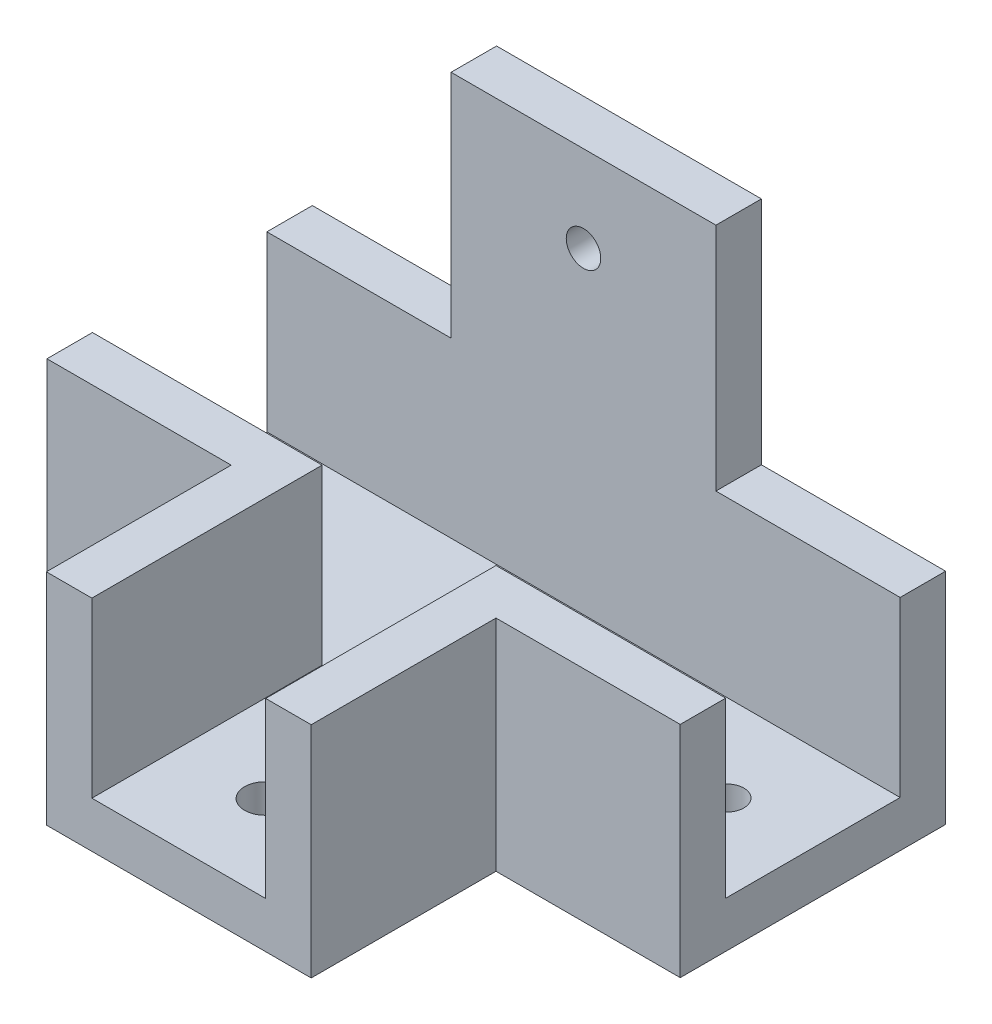
from build123d import *

# Parameters (mm, degrees)
SKETCH_1_W          = 55
SKETCH_1_H          = 19.1
EXTRUDE_1_DEPTH     = 4
SKETCH_2_W          = 55
SKETCH_2_H          = 3.95
EXTRUDE_2_DEPTH     = 15.05
EXTRUDE_3_DEPTH     = 4
SKETCH_4_W          = 3.95
SKETCH_4_H          = 16.05
SKETCH_4_W_2        = 16
SKETCH_4_H_2        = 3.95
EXTRUDE_4_DEPTH     = 15.05
SKETCH_5_W          = 23
SKETCH_5_H          = 20
EXTRUDE_5_DEPTH     = 3.95
SKETCH_6_R          = 1.5
CUT_EXTRUDE_1_DEPTH = 4
SKETCH_7_R          = 1.5
SKETCH_7_R_2        = 1.78505628
CUT_EXTRUDE_2_DEPTH = 4


with BuildPart() as part:
    # 草图1 → 凸台-拉伸1 (new body)
    with BuildSketch(Plane(origin=(0, 0, 0), x_dir=(1, 0, 0), z_dir=(0, 1, 0))):
        with Locations((-13.411439114, 8.064760148)):
            Rectangle(SKETCH_1_W, SKETCH_1_H)
    extrude(amount=EXTRUDE_1_DEPTH)

    # 草图2 → 凸台-拉伸2 (add)
    with BuildSketch(Plane(origin=(0, 4, 0), x_dir=(1, 0, 0), z_dir=(0, 1, 0))):
        with Locations((-13.411439114, 15.639760148)):
            Rectangle(SKETCH_2_W, SKETCH_2_H)
    extrude(amount=EXTRUDE_2_DEPTH)



with BuildPart() as body_2:
    # 草图3 → 凸台-拉伸3 (new body)
    with BuildSketch(Plane.XZ):
        Polygon((-40.911439114, 5.435239852), (-40.911439114, 1.485239852), (-28.911439114, 1.485239852), (-5.911439114, 1.485239852), (14.088560886, 1.485239852), (14.088560886, 5.435239852), (-1.911439114, 5.435239852), (-1.911439114, 21.485239852), (-24.911439114, 21.485239852), (-24.911439114, 5.435239852), align=None)
    extrude(amount=-EXTRUDE_3_DEPTH)


with BuildPart() as part_1:
    add(part.part)

    add(body_2.part)  # 凸台-拉伸4 merges body 2
    # 草图4 → 凸台-拉伸4 (add)
    with BuildSketch(Plane(origin=(0, 4, 0), x_dir=(1, 0, 0), z_dir=(0, 1, 0))):
        with Locations((-3.886439114, -13.460239852)):
            Rectangle(SKETCH_4_W, SKETCH_4_H)
        Polygon((-1.911439114, -5.435239852), (14.088560886, -5.435239852), (14.088560886, -1.485239852), (-5.861439114, -1.485239852), (-5.861439114, -5.435239852), align=None)
        Polygon((-20.961439114, -21.485239852), (-20.961439114, -1.485239852), (-24.911439114, -1.485239852), (-24.911439114, -5.435239852), (-24.911439114, -21.485239852), align=None)
        with Locations((-32.911439114, -3.460239852)):
            Rectangle(SKETCH_4_W_2, SKETCH_4_H_2)
    extrude(amount=EXTRUDE_4_DEPTH)

    # 草图5 → 凸台-拉伸5 (add)
    with BuildSketch(Plane(origin=(0, 0, -17.614760148), x_dir=(-1, 0, 0), z_dir=(0, 0, -1))):
        with Locations((13.411439114, 29.05)):
            Rectangle(SKETCH_5_W, SKETCH_5_H)
    extrude(amount=-EXTRUDE_5_DEPTH)

    # 草图6 → 切除-拉伸1 (cut)
    with BuildSketch(Plane(origin=(0, 0, -17.614760148), x_dir=(-1, 0, 0), z_dir=(0, 0, -1))):
        with Locations((13.411439114, 31.55)):
            Circle(SKETCH_6_R)
    extrude(amount=-CUT_EXTRUDE_1_DEPTH, mode=Mode.SUBTRACT)

    # 草图7 → 切除-拉伸2 (cut)
    with BuildSketch(Plane.XZ):
        with Locations((6.588560886, -6.089760148)):
            Circle(SKETCH_7_R)
        with Locations((-33.411439114, -6.089760148)):
            Circle(SKETCH_7_R)
        with Locations((-13.411439114, 13.985239852)):
            Circle(SKETCH_7_R_2)
    extrude(amount=-CUT_EXTRUDE_2_DEPTH, mode=Mode.SUBTRACT)


solid = part_1.part
